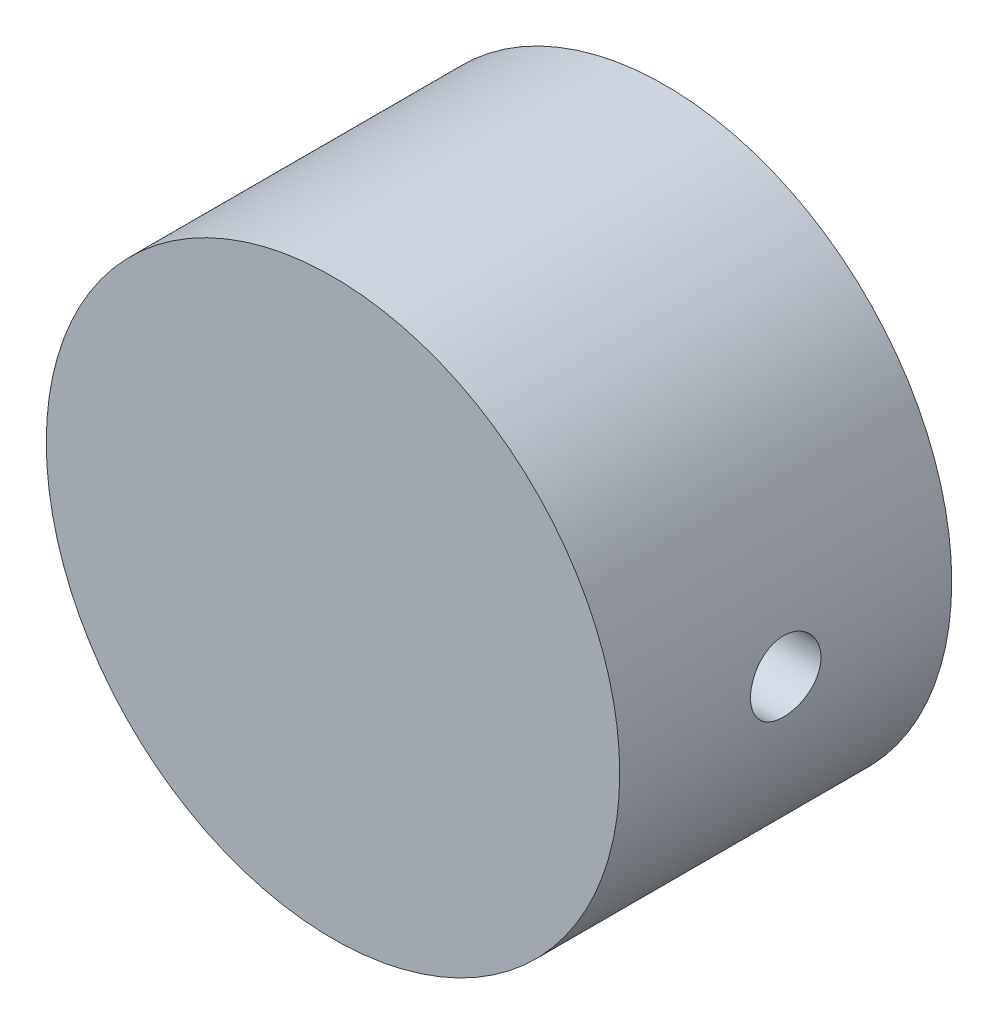
from build123d import *

# Parameters (mm, degrees)
ESQUISSE1_R                  = 28.5
BOSS_EXTRU_1_DEPTH           = 33
ESQUISSE6_R                  = 3.5
ENL_V_MAT_EXTRU_2_DEPTH      = 29.5
ENL_V_MAT_EXTRU_2_DEPTH_BACK = 29.5


with BuildPart() as part:
    # Esquisse1 → Boss.-Extru.1 (new body)
    with BuildSketch(Plane.XY):
        Circle(ESQUISSE1_R)
    extrude(amount=BOSS_EXTRU_1_DEPTH)

    # Esquisse6 → Enlèv. mat.-Extru.2 (cut, two sides)
    with BuildSketch(Plane.ZY) as enl_v_mat_extru_2_sk:
        with Locations((16.5, 0)):
            Circle(ESQUISSE6_R)
    extrude(amount=ENL_V_MAT_EXTRU_2_DEPTH, mode=Mode.SUBTRACT)
    extrude(enl_v_mat_extru_2_sk.sketch, amount=-ENL_V_MAT_EXTRU_2_DEPTH_BACK, mode=Mode.SUBTRACT)


solid = part.part
